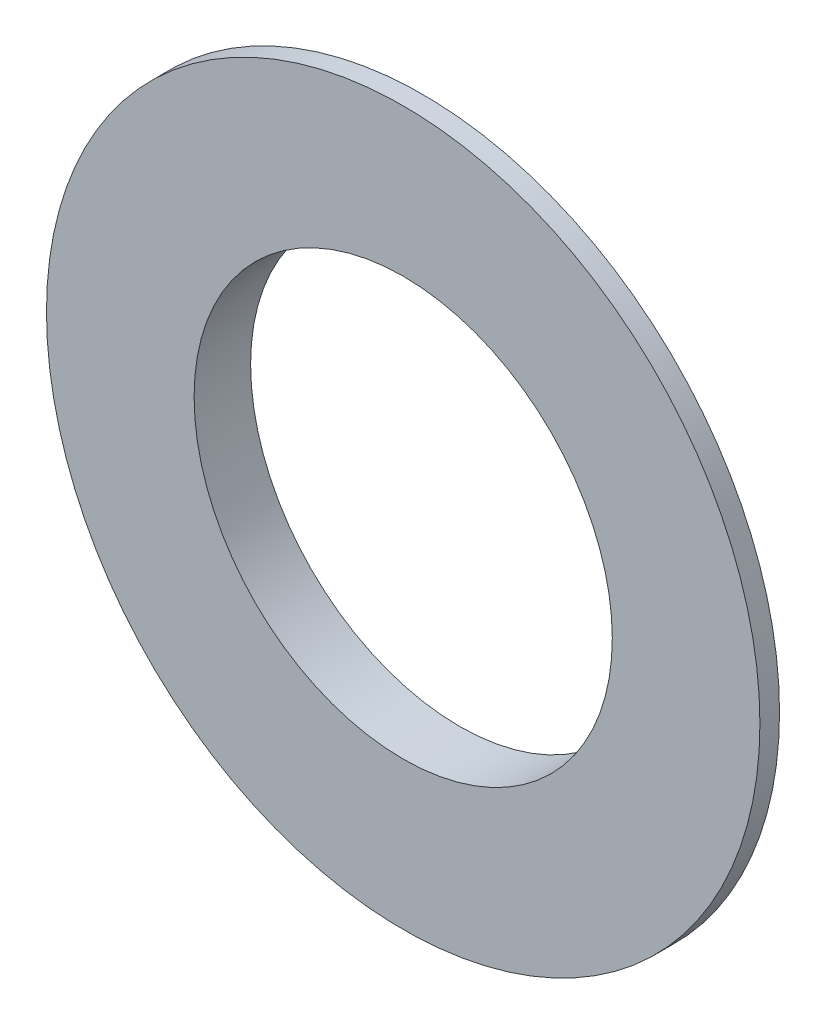
from build123d import *


with BuildPart() as part:
    # Sketch1 → Revolve1 (revolve)
    with BuildSketch(Plane(origin=(0, 0, 0), x_dir=(1, 0, 0), z_dir=(0, 1, 0))):
        Polygon((-18.936734694, 0), (-18.936734694, 1.040816327), (-11.1, 3), (-11.1, 0), align=None)
    revolve(axis=Axis((0, 0, 0), (0, 0, -1)))


solid = part.part
